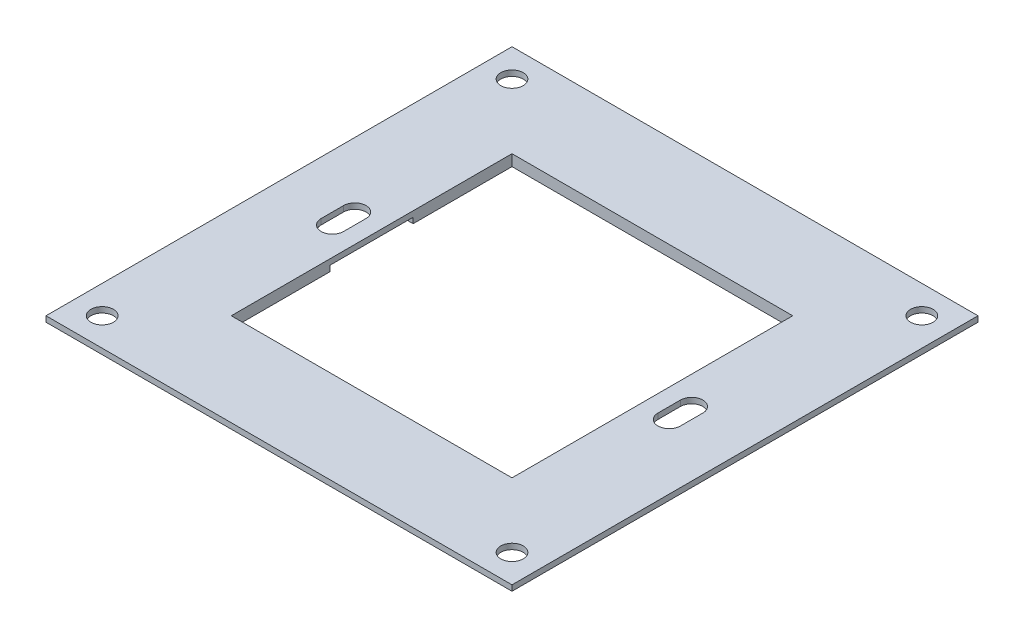
from build123d import *

# Parameters (mm, degrees)
SKETCH_1_W      = 83
SKETCH_1_H      = 83
SKETCH_1_R      = 2
SKETCH_1_W_2    = 50
SKETCH_1_H_2    = 50
EXTRUDE_1_DEPTH = 1
EXTRUDE_2_DEPTH = 1


with BuildPart() as part:
    # Эскиз1 → Бобышка-Вытянуть1 (new body)
    with BuildSketch(Plane(origin=(0, 0, 0), x_dir=(1, 0, 0), z_dir=(0, 1, 0))):
        Rectangle(SKETCH_1_W, SKETCH_1_H)
        with Locations((36.5, 36.5)):
            Circle(SKETCH_1_R, mode=Mode.SUBTRACT)
        with Locations((-36.5, 36.5)):
            Circle(SKETCH_1_R, mode=Mode.SUBTRACT)
        with Locations((-36.5, -36.5)):
            Circle(SKETCH_1_R, mode=Mode.SUBTRACT)
        with Locations((36.5, -36.5)):
            Circle(SKETCH_1_R, mode=Mode.SUBTRACT)
        with BuildLine():
            Line((28, 2), (28, -2))
            ThreePointArc((28, -2), (30, -4), (32, -2))
            Line((32, -2), (32, 2))
            ThreePointArc((32, 2), (30, 4), (28, 2))
        make_face(mode=Mode.SUBTRACT)
        Rectangle(SKETCH_1_W_2, SKETCH_1_H_2, mode=Mode.SUBTRACT)
        with BuildLine():
            Line((-32, 2), (-32, -2))
            ThreePointArc((-32, -2), (-30, -4), (-28, -2))
            Line((-28, -2), (-28, 2))
            ThreePointArc((-28, 2), (-30, 4), (-32, 2))
        make_face(mode=Mode.SUBTRACT)
    extrude(amount=EXTRUDE_1_DEPTH)

    # Эскиз2 → Бобышка-Вытянуть2 (add)
    with BuildSketch(Plane(origin=(0, 0, 0), x_dir=(1, 0, 0), z_dir=(0, 1, 0))):
        with BuildLine():
            Line((-25, -7.393137128), (-34, -7.393137128))
            Line((-34, -7.393137128), (-34, -32))
            ThreePointArc((-34, -32), (-33.414213562, -33.414213562), (-32, -34))
            Line((-32, -34), (32, -34))
            ThreePointArc((32, -34), (33.414213562, -33.414213562), (34, -32))
            Line((34, -32), (34, -7.393137128))
            Line((34, -7.393137128), (25, -7.393137128))
            Line((25, -7.393137128), (25, -25))
            Line((25, -25), (-25, -25))
            Line((-25, -25), (-25, -7.393137128))
        make_face()
        with BuildLine():
            Line((-25, 25), (-25, 7.393137128))
            Line((-25, 7.393137128), (-34, 7.393137128))
            Line((-34, 7.393137128), (-34, 32))
            ThreePointArc((-34, 32), (-33.414213562, 33.414213562), (-32, 34))
            Line((-32, 34), (32, 34))
            ThreePointArc((32, 34), (33.414213562, 33.414213562), (34, 32))
            Line((34, 32), (34, 7.393137128))
            Line((34, 7.393137128), (25, 7.393137128))
            Line((25, 7.393137128), (25, 25))
            Line((25, 25), (-25, 25))
        make_face()
    extrude(amount=-EXTRUDE_2_DEPTH)


solid = part.part
